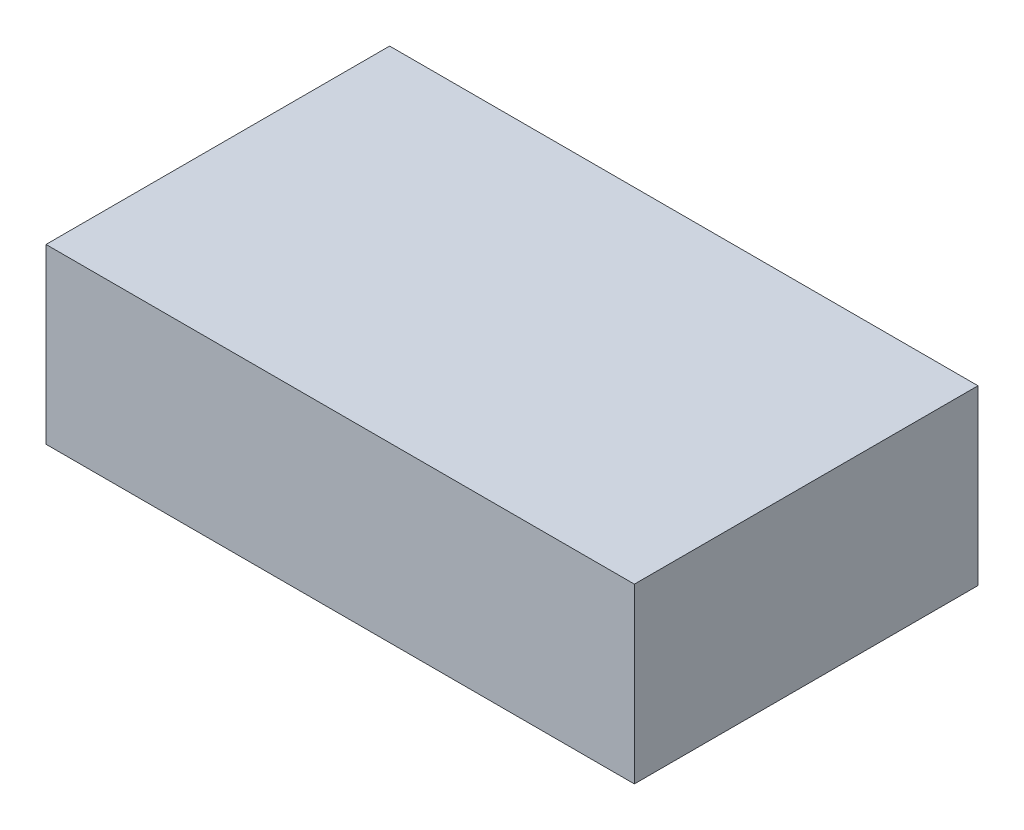
from build123d import *

# Parameters (mm, degrees)
SKETCH1_W           = 238
SKETCH1_H           = 139
BOSS_EXTRUDE1_DEPTH = 70


with BuildPart() as part:
    # Sketch1 → Boss-Extrude1 (new body)
    with BuildSketch(Plane(origin=(0, 0, 0), x_dir=(1, 0, 0), z_dir=(0, 1, 0))):
        with Locations((119, 69.5)):
            Rectangle(SKETCH1_W, SKETCH1_H)
    extrude(amount=BOSS_EXTRUDE1_DEPTH)


solid = part.part
